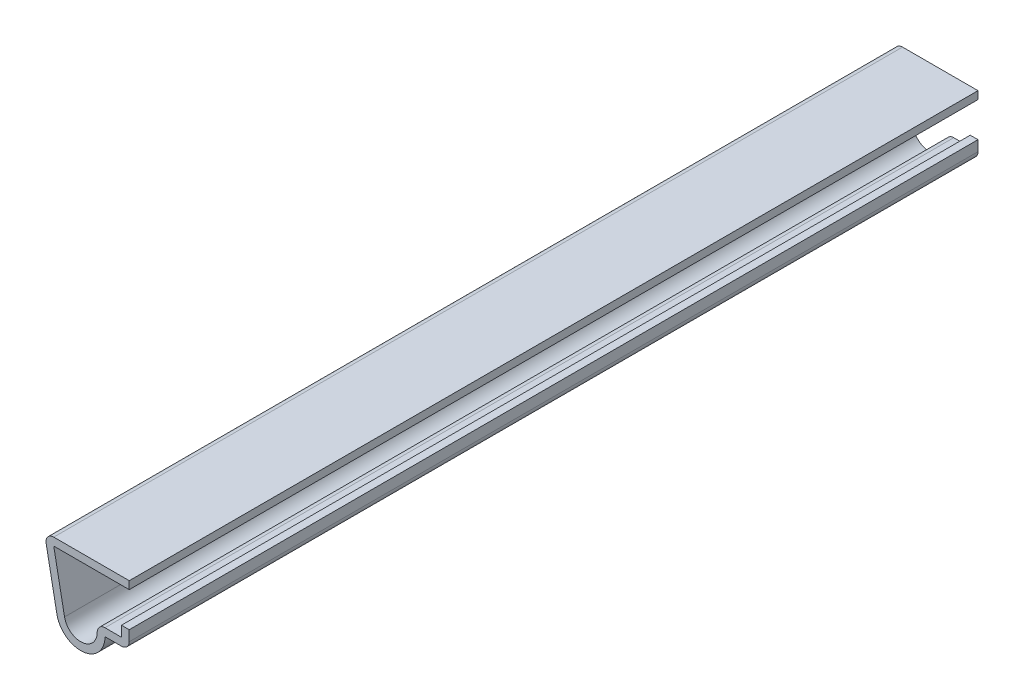
from build123d import *

# Parameters (mm, degrees)
EXTRUDE_THIN1_DEPTH = 111.125
FILLET1_R           = 1.016


with BuildPart() as part:
    # Sketch1 → Extrude-Thin1 (new body)
    with BuildSketch(Plane.XY):
        with BuildLine():
            Line((0, 2.38125), (0, 0))
            Line((0, 0), (-3.175, 0))
            ThreePointArc((-3.175, 0), (-6.048332705, -3.160636303), (-9.467675177, -0.600605106))
            Line((-9.467675177, -0.600605106), (-11.1125, 7.9375))
            Line((-11.1125, 7.9375), (0, 7.9375))
            Line((0, 7.9375), (0, 6.9215))
            Line((0, 6.9215), (-9.882091259, 6.9215))
            Line((-9.882091259, 6.9215), (-8.47001912, -0.408411472))
            ThreePointArc((-8.47001912, -0.408411472), (-5.629725527, -2.035309727), (-4.445, 1.016))
            Line((-4.445, 1.016), (-1.016, 1.016))
            Line((-1.016, 1.016), (-1.016, 2.38125))
            Line((-1.016, 2.38125), (0, 2.38125))
        make_face()
    extrude(amount=-EXTRUDE_THIN1_DEPTH)

    # Fillet1
    fillet1_edges = [part.edges().sort_by_distance(p)[0] for p in [
        (-4.445, 1.016, -55.5625),
        (0, 0, -55.5625),
        (-11.1125, 7.9375, -55.5625),
    ]]
    fillet(fillet1_edges, radius=FILLET1_R)


solid = part.part
